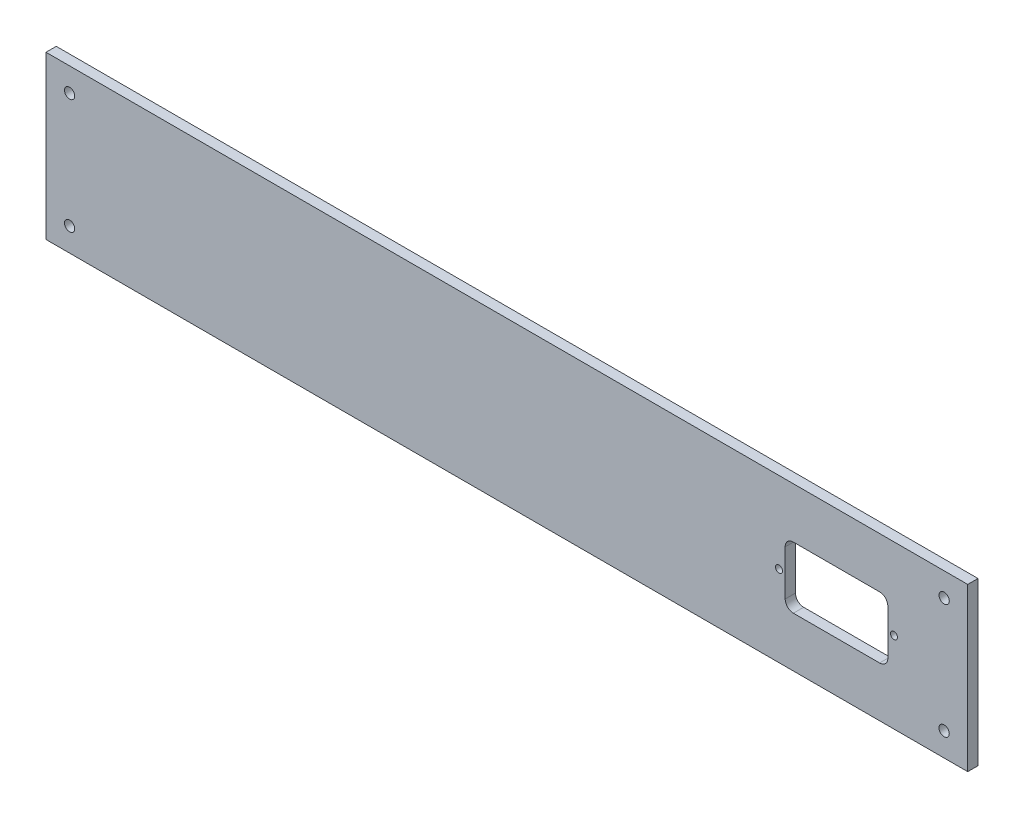
from build123d import *

# Parameters (mm, degrees)
SKETCH_F_W                   = 449
SKETCH_F_H                   = 79
SKETCH_F_R                   = 2.5
ESTRUSIONE_ESTRUSIONE1_DEPTH = 5
SKETCH1_R                    = 1.7
EXTRUDE1_DEPTH               = 6


with BuildPart() as part:
    # Sketch f → Estrusione-Estrusione1 (new body)
    with BuildSketch(Plane.XY):
        with Locations((224.5, 39.5)):
            Rectangle(SKETCH_F_W, SKETCH_F_H)
        with Locations((11.5, 67.5)):
            Circle(SKETCH_F_R, mode=Mode.SUBTRACT)
        with Locations((437.5, 67.5)):
            Circle(SKETCH_F_R, mode=Mode.SUBTRACT)
        with Locations((11.5, 11.5)):
            Circle(SKETCH_F_R, mode=Mode.SUBTRACT)
        with Locations((437.5, 11.5)):
            Circle(SKETCH_F_R, mode=Mode.SUBTRACT)
    extrude(amount=ESTRUSIONE_ESTRUSIONE1_DEPTH)

    # Sketch1 → Extrude1 (cut, through all)
    with BuildSketch(Plane(origin=(0, 0, 0), x_dir=(-1, 0, 0), z_dir=(0, 0, -1))):
        with Locations((-413.061242298, 39.505506417)):
            Circle(SKETCH1_R)
        with Locations((-357.061242298, 39.505506417)):
            Circle(SKETCH1_R)
        with BuildLine():
            Line((-364.0746338, 54.394920259), (-406.0746338, 54.394920259))
            ThreePointArc((-406.0746338, 54.394920259), (-408.903060925, 53.223347384), (-410.0746338, 50.394920259))
            Line((-410.0746338, 50.394920259), (-410.0746338, 28.394920259))
            ThreePointArc((-410.0746338, 28.394920259), (-408.903060925, 25.566493134), (-406.0746338, 24.394920259))
            Line((-406.0746338, 24.394920259), (-364.0746338, 24.394920259))
            ThreePointArc((-364.0746338, 24.394920259), (-361.246206675, 25.566493134), (-360.0746338, 28.394920259))
            Line((-360.0746338, 28.394920259), (-360.0746338, 50.394920259))
            ThreePointArc((-360.0746338, 50.394920259), (-361.246206675, 53.223347384), (-364.0746338, 54.394920259))
        make_face()
    extrude(amount=-EXTRUDE1_DEPTH, mode=Mode.SUBTRACT)


solid = part.part
